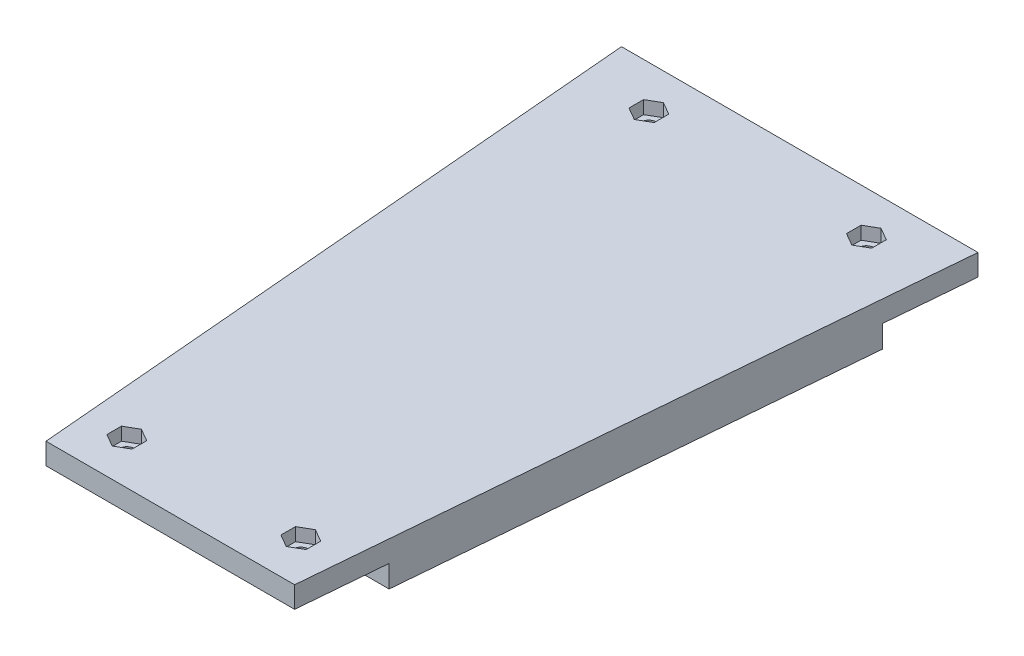
from build123d import *

# Parameters (mm, degrees)
SKETCH1_R           = 50
BOSS_EXTRUDE1_DEPTH = 10
SKETCH2_R           = 20
CUT_EXTRUDE1_DEPTH  = 5
CUT_EXTRUDE6_DEPTH  = 3
SKETCH8_R           = 1.7
CUT_EXTRUDE7_DEPTH  = 10
BOSS_EXTRUDE3_DEPTH = 10
SKETCH10_W          = 21
SKETCH10_H          = 41
CUT_EXTRUDE8_DEPTH  = 10
SKETCH11_W          = 21
SKETCH11_H          = 6.5
CUT_EXTRUDE9_DEPTH  = 1.5
SKETCH12_R          = 1.7
CUT_EXTRUDE10_DEPTH = 9
CUT_EXTRUDE11_DEPTH = 10
SKETCH15_W          = 131.735170003
SKETCH15_H          = 179.266555965
CUT_EXTRUDE12_DEPTH = 79
BOSS_EXTRUDE4_DEPTH = 4.9
SKETCH17_R          = 1.7
CUT_EXTRUDE13_DEPTH = 10
CUT_EXTRUDE14_DEPTH = 3
SKETCH19_W          = 78.571428572
SKETCH19_H          = 5.1
CUT_EXTRUDE15_DEPTH = 0.5
SKETCH20_W          = 92.611657501
SKETCH20_H          = 114.528704683
CUT_EXTRUDE16_DEPTH = 10
CUT_EXTRUDE17_DEPTH = 5.1
SKETCH22_R          = 1.7
CUT_EXTRUDE18_DEPTH = 5.1
CUT_EXTRUDE19_DEPTH = 3


with BuildPart() as part:
    # Sketch1 → Boss-Extrude1 (new body)
    with BuildSketch(Plane(origin=(0, 0, 0), x_dir=(1, 0, 0), z_dir=(0, 1, 0))):
        Circle(SKETCH1_R)
    extrude(amount=BOSS_EXTRUDE1_DEPTH)

    # Sketch2 → Cut-Extrude1 (cut)
    with BuildSketch(Plane(origin=(0, 10, 0), x_dir=(1, 0, 0), z_dir=(0, 1, 0))):
        Circle(SKETCH2_R)
    extrude(amount=-CUT_EXTRUDE1_DEPTH, mode=Mode.SUBTRACT)

    # Sketch7 → Cut-Extrude6 (cut)
    with BuildSketch(Plane.XZ):
        with BuildLine():
            ThreePointArc((-2.85, 14.726761355), (0, 15), (2.85, 14.726761355))
            Line((2.85, 14.726761355), (2.85, 16.645448267))
            Line((2.85, 16.645448267), (0, 18.290896534))
            Line((0, 18.290896534), (-2.85, 16.645448267))
            Line((-2.85, 16.645448267), (-2.85, 14.726761355))
        make_face()
        with BuildLine():
            Line((2.85, 13.354551733), (2.85, 14.726761355))
            ThreePointArc((2.85, 14.726761355), (0, 15), (-2.85, 14.726761355))
            Line((-2.85, 14.726761355), (-2.85, 13.354551733))
            Line((-2.85, 13.354551733), (0, 11.709103466))
            Line((0, 11.709103466), (2.85, 13.354551733))
        make_face()
        Polygon((-12.990381057, -4.209103466), (-15.840381057, -5.854551733), (-15.840381057, -9.145448267), (-12.990381057, -10.790896534), (-10.140381057, -9.145448267), (-10.140381057, -5.854551733), align=None)
        Polygon((15.840381057, -5.854551733), (12.990381057, -4.209103466), (10.140381057, -5.854551733), (10.140381057, -9.145448267), (12.990381057, -10.790896534), (15.840381057, -9.145448267), align=None)
    extrude(amount=-CUT_EXTRUDE6_DEPTH, mode=Mode.SUBTRACT)

    # Sketch8 → Cut-Extrude7 (cut)
    with BuildSketch(Plane.XZ):
        with Locations((0, 15)):
            Circle(SKETCH8_R)
        with Locations((12.990381057, -7.5)):
            Circle(SKETCH8_R)
        with Locations((-12.990381057, -7.5)):
            Circle(SKETCH8_R)
    extrude(amount=-CUT_EXTRUDE7_DEPTH, mode=Mode.SUBTRACT)


with BuildPart() as body_2:
    # Sketch9 → Boss-Extrude3 (new body)
    with BuildSketch(Plane.XZ):
        with BuildLine():
            Line((-50, 350), (-50, 0))
            ThreePointArc((-50, 0), (0, 50), (50, 0))
            Line((50, 0), (50, 350))
            Line((50, 350), (-50, 350))
        make_face()
    extrude(amount=-BOSS_EXTRUDE3_DEPTH)

    # Sketch10 → Cut-Extrude8 (cut)
    with BuildSketch(Plane.XZ):
        with Locations((0, 319.5)):
            Rectangle(SKETCH10_W, SKETCH10_H)
    extrude(amount=-CUT_EXTRUDE8_DEPTH, mode=Mode.SUBTRACT)

    # Sketch11 → Cut-Extrude9 (cut)
    with BuildSketch(Plane.XZ):
        with Locations((0, 343.25)):
            Rectangle(SKETCH11_W, SKETCH11_H)
        with Locations((0, 295.75)):
            Rectangle(SKETCH11_W, SKETCH11_H)
    extrude(amount=-CUT_EXTRUDE9_DEPTH, mode=Mode.SUBTRACT)

    # Sketch12 → Cut-Extrude10 (cut)
    with BuildSketch(Plane.XZ.offset(-1.5)):
        with Locations((-5, 343.75)):
            Circle(SKETCH12_R)
        with Locations((5, 343.75)):
            Circle(SKETCH12_R)
        with Locations((-5, 295.25)):
            Circle(SKETCH12_R)
        with Locations((5, 295.25)):
            Circle(SKETCH12_R)
    extrude(amount=-CUT_EXTRUDE10_DEPTH, mode=Mode.SUBTRACT)

    # Sketch13 → Cut-Extrude11 (cut)
    with BuildSketch(Plane.XZ):
        with BuildLine():
            Line((-50, 350), (-50, 0))
            ThreePointArc((-50, 0), (-49.817332452, 4.270057067), (-49.270664506, 8.5089141))
            Line((-49.270664506, 8.5089141), (-20, 350))
            Line((-20, 350), (-50, 350))
        make_face()
        with BuildLine():
            Line((20, 350), (49.270664506, 8.5089141))
            ThreePointArc((49.270664506, 8.5089141), (49.817332452, 4.270057067), (50, 0))
            Line((50, 0), (50, 350))
            Line((50, 350), (20, 350))
        make_face()
    extrude(amount=-CUT_EXTRUDE11_DEPTH, mode=Mode.SUBTRACT)


with BuildPart() as cut_extrude12_tool:
    # Sketch15 → Cut-Extrude12 (new body)
    with BuildSketch(Plane(origin=(0, 10, 0), x_dir=(1, 0, 0), z_dir=(0, 1, 0))):
        with Locations((-8.166136658, -35.366722018)):
            Rectangle(SKETCH15_W, SKETCH15_H)
    extrude(amount=-CUT_EXTRUDE12_DEPTH)


with BuildPart() as part_1:
    add(part.part)

    # Cut-Extrude12: cut by cut_extrude12_tool
    add(cut_extrude12_tool.part, mode=Mode.SUBTRACT)


with BuildPart() as body_2_1:
    add(body_2.part)

    # Cut-Extrude12: cut by cut_extrude12_tool
    add(cut_extrude12_tool.part, mode=Mode.SUBTRACT)

    # Sketch16 → Boss-Extrude4 (add)
    with BuildSketch(Plane(origin=(0, 10, 0), x_dir=(1, 0, 0), z_dir=(0, 1, 0))):
        Polygon((40.972386827, -105.322153681), (-40.972386827, -105.322153681), (-39.285714286, -125), (39.285714286, -125), align=None)
    extrude(amount=-BOSS_EXTRUDE4_DEPTH)

    # Sketch17 → Cut-Extrude13 (cut)
    with BuildSketch(Plane.XZ.offset(-5.1)):
        with Locations((-25, 115)):
            Circle(SKETCH17_R)
        with Locations((25, 115)):
            Circle(SKETCH17_R)
    extrude(amount=-CUT_EXTRUDE13_DEPTH, mode=Mode.SUBTRACT)

    # Sketch18 → Cut-Extrude14 (cut)
    with BuildSketch(Plane(origin=(0, 10, 0), x_dir=(1, 0, 0), z_dir=(0, 1, 0))):
        Polygon((-25, -111.651368439), (-27.9, -113.325684219), (-27.9, -116.674315781), (-25, -118.348631561), (-22.1, -116.674315781), (-22.1, -113.325684219), align=None)
        Polygon((22.1, -113.325684219), (25, -111.651368439), (27.9, -113.325684219), (27.9, -116.674315781), (25, -118.348631561), (22.1, -116.674315781), align=None)
    extrude(amount=-CUT_EXTRUDE14_DEPTH, mode=Mode.SUBTRACT)

    # Sketch19 → Cut-Extrude15 (cut)
    with BuildSketch(Plane(origin=(0, 0, 125), x_dir=(-1, 0, 0), z_dir=(0, 0, -1))):
        with Locations((0, 2.55)):
            Rectangle(SKETCH19_W, SKETCH19_H)
    extrude(amount=-CUT_EXTRUDE15_DEPTH, mode=Mode.SUBTRACT)

    # Sketch20 → Cut-Extrude16 (cut)
    with BuildSketch(Plane.XZ):
        with Locations((0.685731612, 307.264352342)):
            Rectangle(SKETCH20_W, SKETCH20_H)
    extrude(amount=-CUT_EXTRUDE16_DEPTH, mode=Mode.SUBTRACT)

    # Sketch21 → Cut-Extrude17 (cut)
    with BuildSketch(Plane.XZ):
        Polygon((-28.571428571, 250), (-30.285714286, 230), (30.285714286, 230), (28.571428571, 250), align=None)
    extrude(amount=-CUT_EXTRUDE17_DEPTH, mode=Mode.SUBTRACT)

    # Sketch22 → Cut-Extrude18 (cut)
    with BuildSketch(Plane.XZ.offset(-5.1)):
        with Locations((-20, 240)):
            Circle(SKETCH22_R)
        with Locations((20, 240)):
            Circle(SKETCH22_R)
    extrude(amount=-CUT_EXTRUDE18_DEPTH, mode=Mode.SUBTRACT)

    # Sketch23 → Cut-Extrude19 (cut)
    with BuildSketch(Plane(origin=(0, 10, 0), x_dir=(1, 0, 0), z_dir=(0, 1, 0))):
        Polygon((-20, -236.651368439), (-22.9, -238.325684219), (-22.9, -241.674315781), (-20, -243.348631561), (-17.1, -241.674315781), (-17.1, -238.325684219), align=None)
        Polygon((17.1, -238.325684219), (20, -236.651368439), (22.9, -238.325684219), (22.9, -241.674315781), (20, -243.348631561), (17.1, -241.674315781), align=None)
    extrude(amount=-CUT_EXTRUDE19_DEPTH, mode=Mode.SUBTRACT)


solid = body_2_1.part
